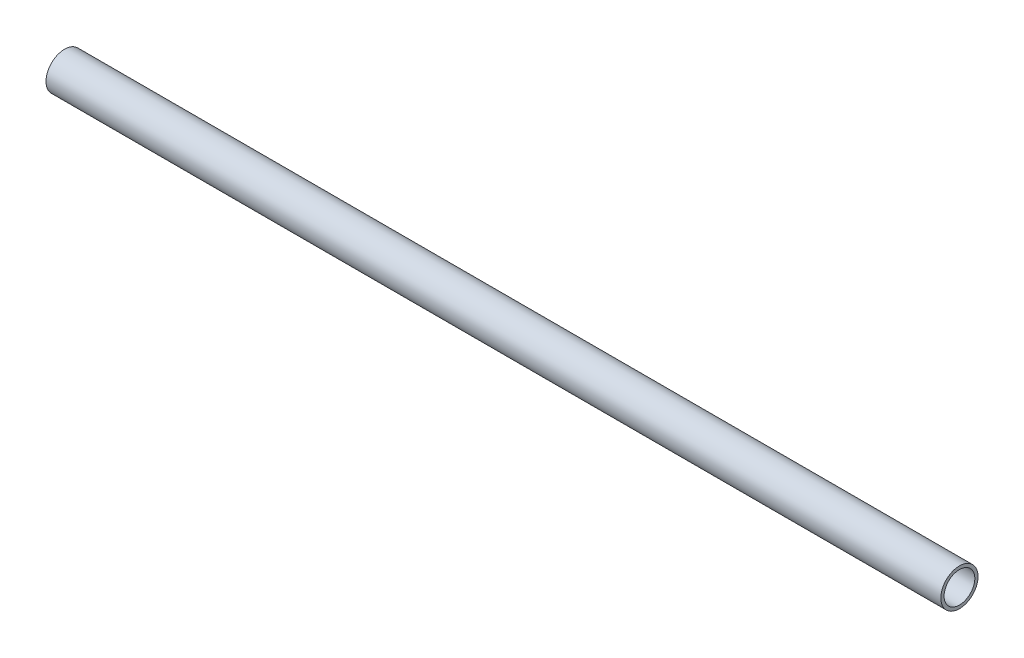
from build123d import *

# Parameters (mm, degrees)
SKETCH2_ONE_SIDE_W = 457.2
SKETCH2_ONE_SIDE_H = 1.651


with BuildPart() as part:
    # Sketch2 one side → Revolve1 (revolve)
    with BuildSketch(Plane(origin=(0, 0, 0), x_dir=(1, 0, 0), z_dir=(0, 1, 0))):
        with Locations((0, 8.670301776)):
            Rectangle(SKETCH2_ONE_SIDE_W, SKETCH2_ONE_SIDE_H)
    revolve(axis=Axis((-228.6, 0, 0), (1, 0, 0)))


solid = part.part
